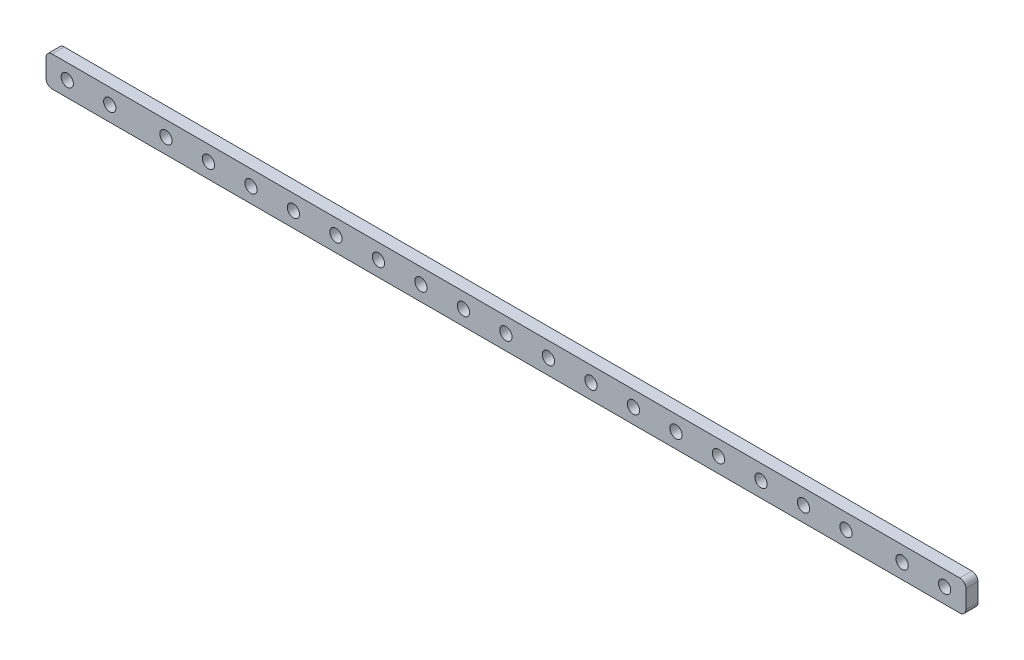
from build123d import *

# Parameters (mm, degrees)
SKETCH_1_W      = 303
SKETCH_1_H      = 10
SKETCH_1_R      = 2.025
EXTRUDE_1_DEPTH = 4
FILLET_1_R      = 2


with BuildPart() as part:
    # 草图1 → 凸台-拉伸1 (new body)
    with BuildSketch(Plane.XY):
        Rectangle(SKETCH_1_W, SKETCH_1_H)
        with Locations((-112, 0)):
            Circle(SKETCH_1_R, mode=Mode.SUBTRACT)
        with Locations((-98, 0)):
            Circle(SKETCH_1_R, mode=Mode.SUBTRACT)
        with Locations((-84, 0)):
            Circle(SKETCH_1_R, mode=Mode.SUBTRACT)
        with Locations((-70, 0)):
            Circle(SKETCH_1_R, mode=Mode.SUBTRACT)
        with Locations((-56, 0)):
            Circle(SKETCH_1_R, mode=Mode.SUBTRACT)
        with Locations((-42, 0)):
            Circle(SKETCH_1_R, mode=Mode.SUBTRACT)
        with Locations((-28, 0)):
            Circle(SKETCH_1_R, mode=Mode.SUBTRACT)
        with Locations((-14, 0)):
            Circle(SKETCH_1_R, mode=Mode.SUBTRACT)
        Circle(SKETCH_1_R, mode=Mode.SUBTRACT)
        with Locations((14, 0)):
            Circle(SKETCH_1_R, mode=Mode.SUBTRACT)
        with Locations((28, 0)):
            Circle(SKETCH_1_R, mode=Mode.SUBTRACT)
        with Locations((42, 0)):
            Circle(SKETCH_1_R, mode=Mode.SUBTRACT)
        with Locations((56, 0)):
            Circle(SKETCH_1_R, mode=Mode.SUBTRACT)
        with Locations((70, 0)):
            Circle(SKETCH_1_R, mode=Mode.SUBTRACT)
        with Locations((84, 0)):
            Circle(SKETCH_1_R, mode=Mode.SUBTRACT)
        with Locations((98, 0)):
            Circle(SKETCH_1_R, mode=Mode.SUBTRACT)
        with Locations((112, 0)):
            Circle(SKETCH_1_R, mode=Mode.SUBTRACT)
        with Locations((-144.5, 0)):
            Circle(SKETCH_1_R, mode=Mode.SUBTRACT)
        with Locations((-130.5, 0)):
            Circle(SKETCH_1_R, mode=Mode.SUBTRACT)
        with Locations((130.5, 0)):
            Circle(SKETCH_1_R, mode=Mode.SUBTRACT)
        with Locations((144.5, 0)):
            Circle(SKETCH_1_R, mode=Mode.SUBTRACT)
    extrude(amount=EXTRUDE_1_DEPTH)

    # 圆角1
    fillet_1_edges = [part.edges().sort_by_distance(p)[0] for p in [
        (151.5, -5, 2),
        (-151.5, -5, 2),
        (-151.5, 5, 2),
        (151.5, 5, 2),
    ]]
    fillet(fillet_1_edges, radius=FILLET_1_R)


solid = part.part
